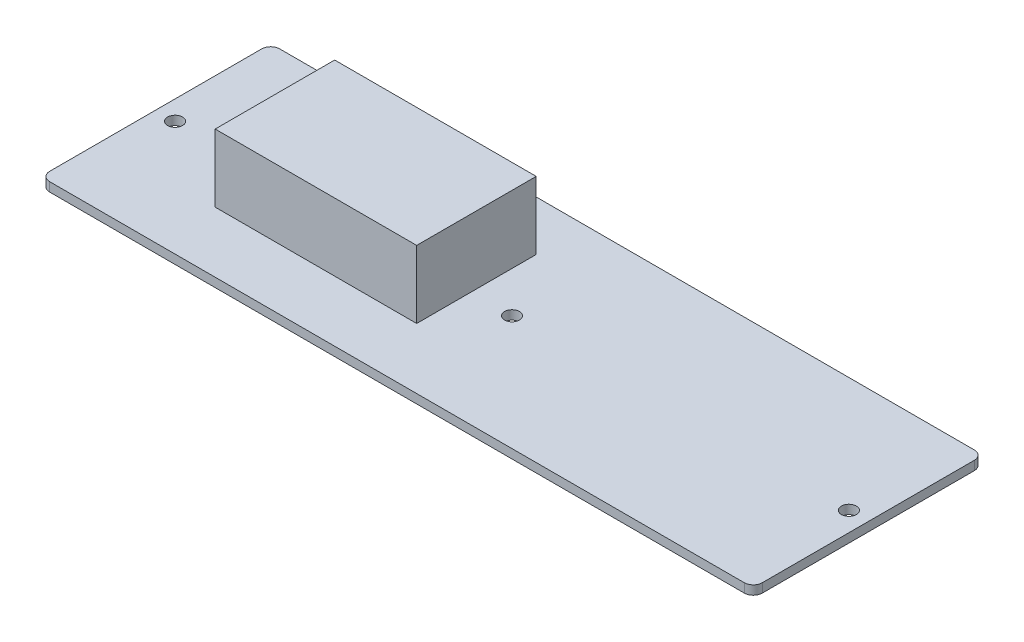
from build123d import *

# Parameters (mm, degrees)
SKETCH1_W           = 158
SKETCH1_H           = 51
BOSS_EXTRUDE1_DEPTH = 2
SKETCH2_R           = 1.65
CUT_EXTRUDE1_DEPTH  = 3
FILLET1_R           = 2
SKETCH3_W           = 44.679431241
SKETCH3_H           = 26.501035196
BOSS_EXTRUDE2_DEPTH = 15


with BuildPart() as part:
    # Sketch1 → Boss-Extrude1 (new body)
    with BuildSketch(Plane(origin=(0, 0, 0), x_dir=(1, 0, 0), z_dir=(0, 1, 0))):
        with Locations((79, 25.5)):
            Rectangle(SKETCH1_W, SKETCH1_H)
    extrude(amount=BOSS_EXTRUDE1_DEPTH)

    # Sketch2 → Cut-Extrude1 (cut, through all)
    with BuildSketch(Plane(origin=(0, 2, 0), x_dir=(1, 0, 0), z_dir=(0, 1, 0))):
        with Locations((4.3, 25.5)):
            Circle(SKETCH2_R)
        with Locations((153.7, 25.5)):
            Circle(SKETCH2_R)
        with Locations((79, 25.5)):
            Circle(SKETCH2_R)
    extrude(amount=-CUT_EXTRUDE1_DEPTH, mode=Mode.SUBTRACT)

    # Fillet1
    fillet1_edges = [part.edges().sort_by_distance(p)[0] for p in [
        (0, 1, -51),
        (158, 1, -51),
        (158, 1, 0),
        (0, 1, 0),
    ]]
    fillet(fillet1_edges, radius=FILLET1_R)

    # Sketch3 → Boss-Extrude2 (add)
    with BuildSketch(Plane(origin=(0, 2, 0), x_dir=(1, 0, 0), z_dir=(0, 1, 0))):
        with Locations((47.571086358, 26.704592509)):
            Rectangle(SKETCH3_W, SKETCH3_H)
    extrude(amount=BOSS_EXTRUDE2_DEPTH)


solid = part.part
